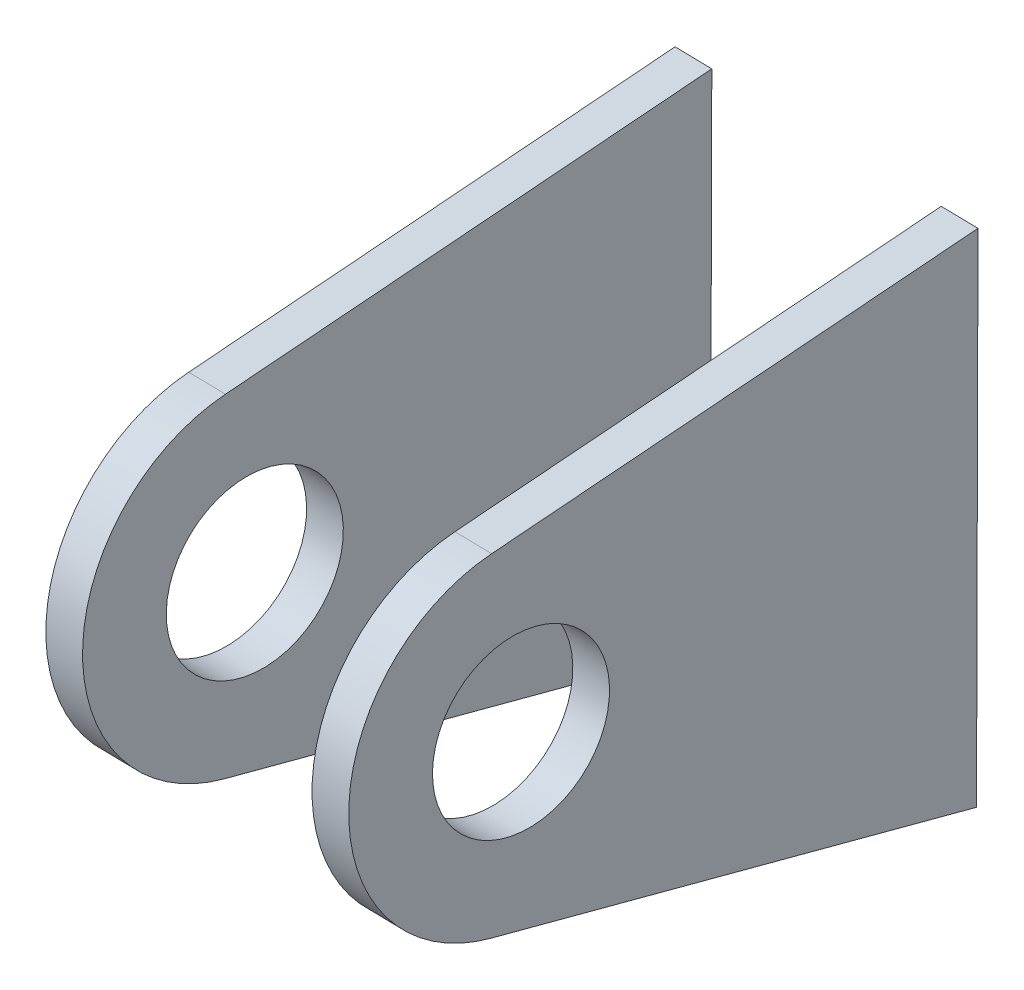
from build123d import *

# Parameters (mm, degrees)
SKETCH1_R           = 3.2639
BOSS_EXTRUDE1_DEPTH = 6.2865
SKETCH1_2_R         = 3.2639
CUT_EXTRUDE1_DEPTH  = 4.7625


with BuildPart() as part:
    # Sketch1 → Boss-Extrude1 (new, symmetric)
    with BuildSketch(Plane(origin=(27.39550281, 1.113566762, 1.602472205), x_dir=(0.05829801557917802, 0.0023696857432327634, -0.9982964118782599), z_dir=(0.9974727182261839, 0.04054506583391268, 0.05834615695135168))):
        with BuildLine():
            Line((-116.668497282, 501.060182643), (-117.446087561, 482.248765825))
            Line((-117.446087561, 482.248765825), (-135.222725421, 486.146492507))
            ThreePointArc((-135.222725421, 486.146492507), (-140.207306403, 492.611405123), (-134.70617374, 498.642879415))
            Line((-134.70617374, 498.642879415), (-116.668497282, 501.060182643))
        make_face()
        with Locations((-133.862724494, 492.349144962)):
            Circle(SKETCH1_R, mode=Mode.SUBTRACT)
    extrude(amount=BOSS_EXTRUDE1_DEPTH, both=True)

    # Sketch1_2 → Cut-Extrude1 (cut, symmetric)
    with BuildSketch(Plane(origin=(27.39550281, 1.113566762, 1.602472205), x_dir=(0.05829801557917802, 0.0023696857432327634, -0.9982964118782599), z_dir=(0.9974727182261839, 0.04054506583391268, 0.05834615695135168))):
        with BuildLine():
            Line((-116.668497282, 501.060182643), (-117.446087561, 482.248765825))
            Line((-117.446087561, 482.248765825), (-135.222725421, 486.146492507))
            ThreePointArc((-135.222725421, 486.146492507), (-140.207306403, 492.611405123), (-134.70617374, 498.642879415))
            Line((-134.70617374, 498.642879415), (-116.668497282, 501.060182643))
        make_face()
        with Locations((-133.862724494, 492.349144962)):
            Circle(SKETCH1_2_R, mode=Mode.SUBTRACT)
    extrude(amount=CUT_EXTRUDE1_DEPTH, both=True, mode=Mode.SUBTRACT)


with BuildPart() as cut_extrude1_piece_1:
    # of the separate pieces the step leaves, piece 1, a body of its own (cut_extrude1_pieces)
    add(part.part.solids().sort_by_distance((-6.980221505, 498.77091844, 135.712368992))[0])


with BuildPart() as cut_extrude1_piece_2:
    # of the separate pieces the step leaves, piece 2, a body of its own (cut_extrude1_pieces)
    add(part.part.solids().sort_by_distance((4.040854559, 499.218900872, 136.35703568))[0])


solid = Compound([cut_extrude1_piece_1.part, cut_extrude1_piece_2.part])
